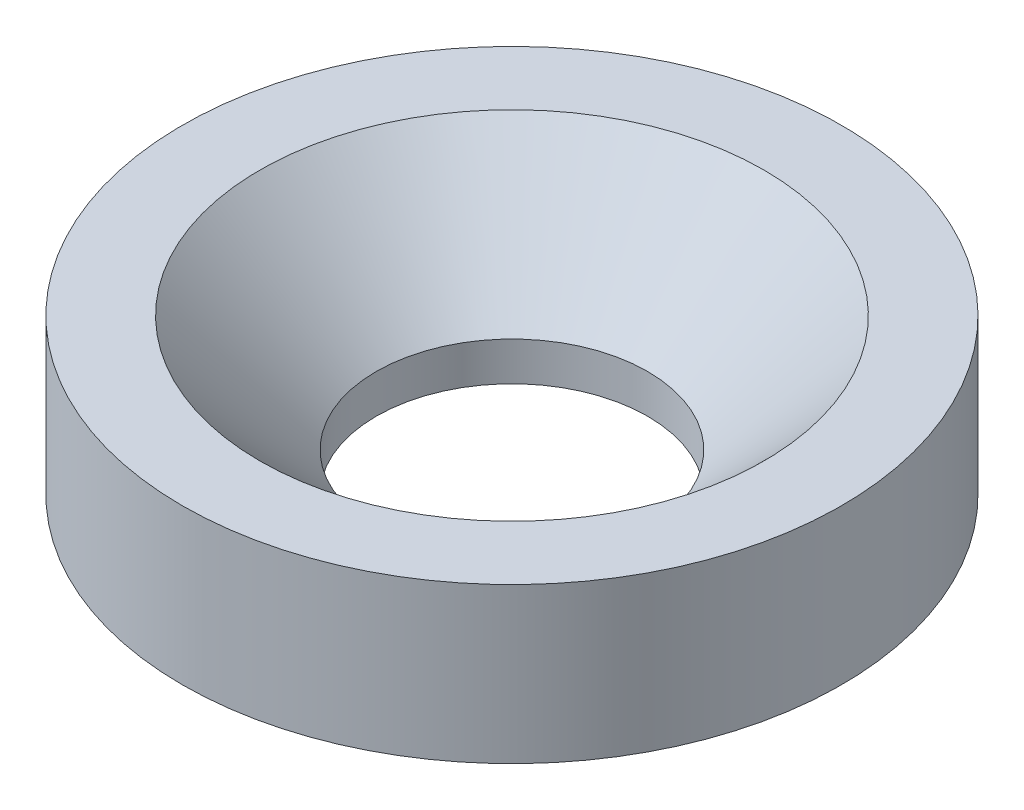
from build123d import *

# Parameters (mm, degrees)
SKETCH1_R           = 4.25
SKETCH1_R_2         = 1.75
BOSS_EXTRUDE1_DEPTH = 2
CHAMFER1_SIZE       = 1.5


with BuildPart() as part:
    # Sketch1 → Boss-Extrude1 (new body)
    with BuildSketch(Plane(origin=(0, 0, 0), x_dir=(1, 0, 0), z_dir=(0, 1, 0))):
        Circle(SKETCH1_R)
        Circle(SKETCH1_R_2, mode=Mode.SUBTRACT)
    extrude(amount=BOSS_EXTRUDE1_DEPTH)

    # Chamfer1
    chamfer1_edges = [part.edges().sort_by_distance(p)[0] for p in [
        (-1.75, 2, 0),
    ]]
    chamfer(chamfer1_edges, length=CHAMFER1_SIZE)


solid = part.part
